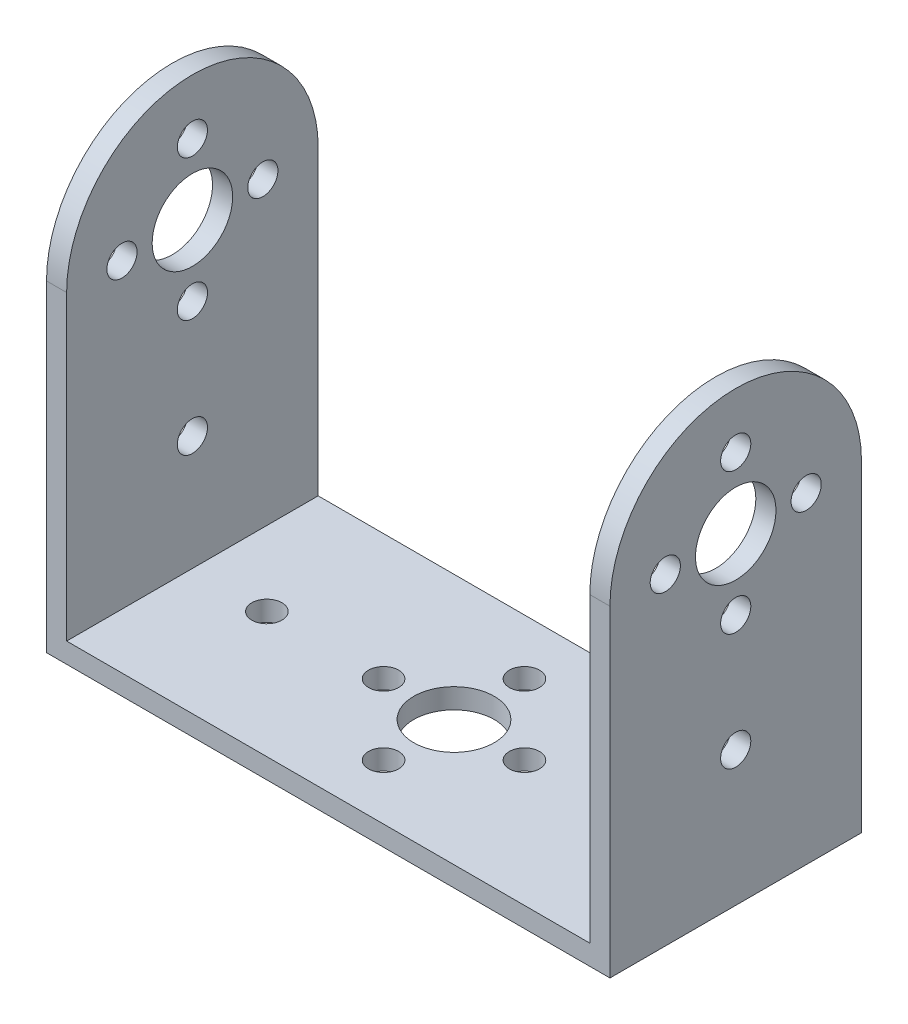
from build123d import *

# Parameters (mm, degrees)
SKETCH1_W           = 52
SKETCH1_H           = 25
BOSS_EXTRUDE1_DEPTH = 2
SKETCH3_R           = 4
SKETCH3_R_2         = 1.5
CUT_EXTRUDE1_DEPTH  = 3
SKETCH4_R           = 4
SKETCH4_R_2         = 1.5
BOSS_EXTRUDE3_DEPTH = 2
SKETCH5_R           = 4
SKETCH5_R_2         = 1.496339982
SKETCH5_R_3         = 1.5
BOSS_EXTRUDE4_DEPTH = 2


with BuildPart() as part:
    # Sketch1 → Boss-Extrude1 (new body)
    with BuildSketch(Plane(origin=(0, 0, 0), x_dir=(1, 0, 0), z_dir=(0, 1, 0))):
        Rectangle(SKETCH1_W, SKETCH1_H)
    extrude(amount=BOSS_EXTRUDE1_DEPTH)

    # Sketch3 → Cut-Extrude1 (cut, through all)
    with BuildSketch(Plane(origin=(0, 2, 0), x_dir=(1, 0, 0), z_dir=(0, 1, 0))):
        Circle(SKETCH3_R)
        with Locations((18.6, 0)):
            Circle(SKETCH3_R_2)
        with Locations((7, 0)):
            Circle(SKETCH3_R_2)
        with Locations((0, 7)):
            Circle(SKETCH3_R_2)
        with Locations((-7, 0)):
            Circle(SKETCH3_R_2)
        with Locations((0, -7)):
            Circle(SKETCH3_R_2)
        with Locations((-18.6, 0)):
            Circle(SKETCH3_R_2)
    extrude(amount=-CUT_EXTRUDE1_DEPTH, mode=Mode.SUBTRACT)

    # Sketch4 → Boss-Extrude3 (add)
    with BuildSketch(Plane(origin=(26, 0, 0), x_dir=(0, 0, -1), z_dir=(1, 0, 0))):
        with BuildLine():
            Line((-12.5, 0), (12.5, 0))
            Line((12.5, 0), (12.5, 32))
            ThreePointArc((12.5, 32), (0, 44.5), (-12.5, 32))
            Line((-12.5, 32), (-12.5, 0))
        make_face()
        with Locations((0, 32)):
            Circle(SKETCH4_R, mode=Mode.SUBTRACT)
        with Locations((0, 39)):
            Circle(SKETCH4_R_2, mode=Mode.SUBTRACT)
        with Locations((7, 32)):
            Circle(SKETCH4_R_2, mode=Mode.SUBTRACT)
        with Locations((0, 25)):
            Circle(SKETCH4_R_2, mode=Mode.SUBTRACT)
        with Locations((-7, 32)):
            Circle(SKETCH4_R_2, mode=Mode.SUBTRACT)
        with Locations((0, 13.4)):
            Circle(SKETCH4_R_2, mode=Mode.SUBTRACT)
    extrude(amount=BOSS_EXTRUDE3_DEPTH)

    # Sketch5 → Boss-Extrude4 (add)
    with BuildSketch(Plane.ZY.offset(26)):
        with BuildLine():
            Line((-12.5, 0), (12.5, 0))
            Line((12.5, 0), (12.5, 32))
            ThreePointArc((12.5, 32), (0, 44.5), (-12.5, 32))
            Line((-12.5, 32), (-12.5, 0))
        make_face()
        with Locations((0, 32)):
            Circle(SKETCH5_R, mode=Mode.SUBTRACT)
        with Locations((0, 39)):
            Circle(SKETCH5_R_2, mode=Mode.SUBTRACT)
        with Locations((7, 32)):
            Circle(SKETCH5_R_3, mode=Mode.SUBTRACT)
        with Locations((0, 25)):
            Circle(SKETCH5_R_3, mode=Mode.SUBTRACT)
        with Locations((-7, 32)):
            Circle(SKETCH5_R_3, mode=Mode.SUBTRACT)
        with Locations((0, 13.4)):
            Circle(SKETCH5_R_3, mode=Mode.SUBTRACT)
    extrude(amount=BOSS_EXTRUDE4_DEPTH)


solid = part.part
